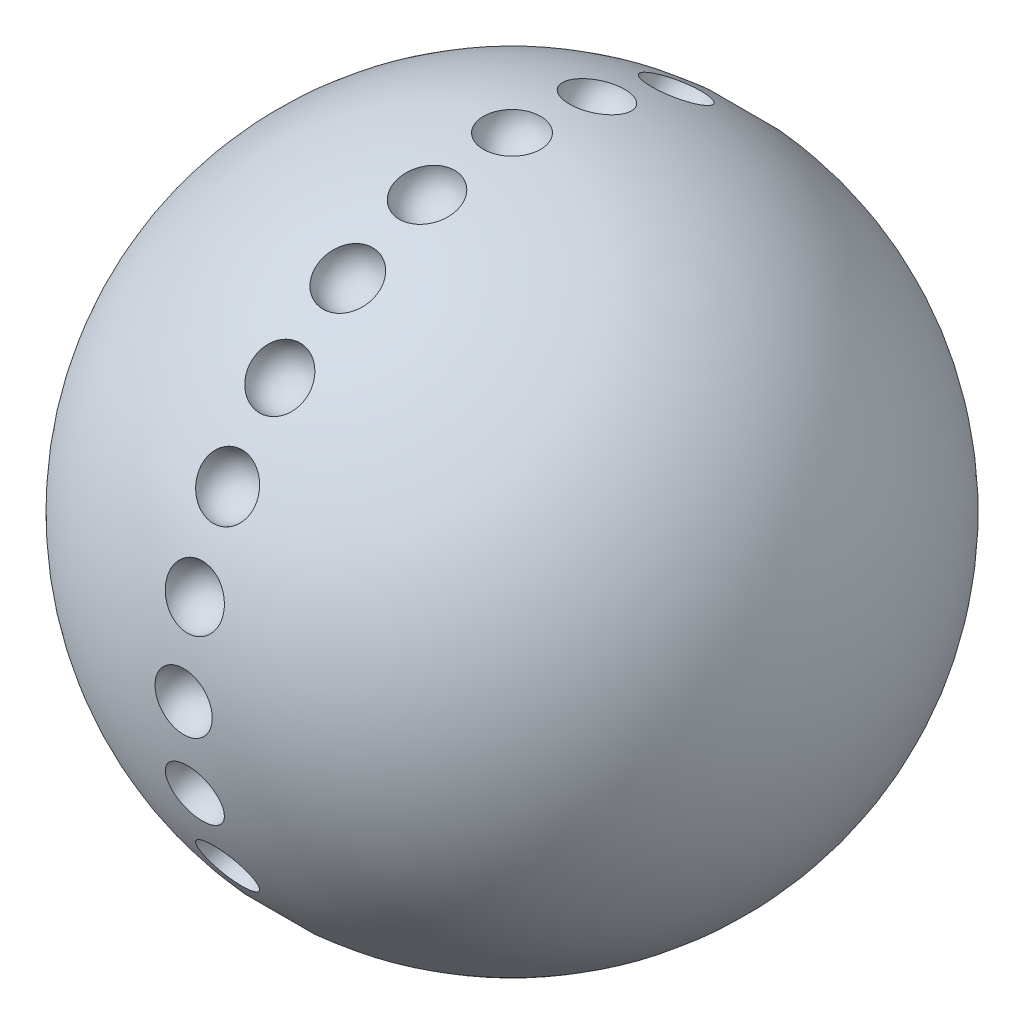
from build123d import *
from build123d.topology import SkipClean

# Parameters (mm, degrees)
CIRPATTERN1_COUNT = 24


with BuildPart() as part:
    # Sketch1 → Revolve1 (revolve)
    with BuildSketch(Plane.XY):
        with BuildLine():
            Line((0, 77.449444527), (0, -77.449444527))
            ThreePointArc((0, -77.449444527), (77.449444527, 0), (0, 77.449444527))
        make_face()
    revolve(axis=Axis((0, 77.449444527, 0), (0, -1, 0)))

    # Sketch2 → Cut-Revolve1 (revolve, cut)
    with SkipClean():  # the faces are left unmerged after this step: merging them gives an invalid solid
        with BuildSketch(Plane(origin=(0, 0, 0), x_dir=(1, 0, 0), z_dir=(0, 1, 0))):
            with BuildLine():
                Line((-6.733086692, 77.449444527), (6.733086692, 77.449444527))
                ThreePointArc((6.733086692, 77.449444527), (0, 70.716357835), (-6.733086692, 77.449444527))
            make_face()
        cut_revolve1 = revolve(axis=Axis((-6.733086692, 0, -77.449444527), (1, 0, 0)), mode=Mode.SUBTRACT)

    # CirPattern1: Cut-Revolve1 ×24 about axis
    with SkipClean():  # the faces are left unmerged after this step: merging them gives an invalid solid
        cirpattern1_axis = Axis((0, 0, 0), (1, 0, 0))
        for i in range(1, CIRPATTERN1_COUNT):
            add(cut_revolve1.rotate(cirpattern1_axis, i * 360 / CIRPATTERN1_COUNT), mode=Mode.SUBTRACT)


solid = part.part
